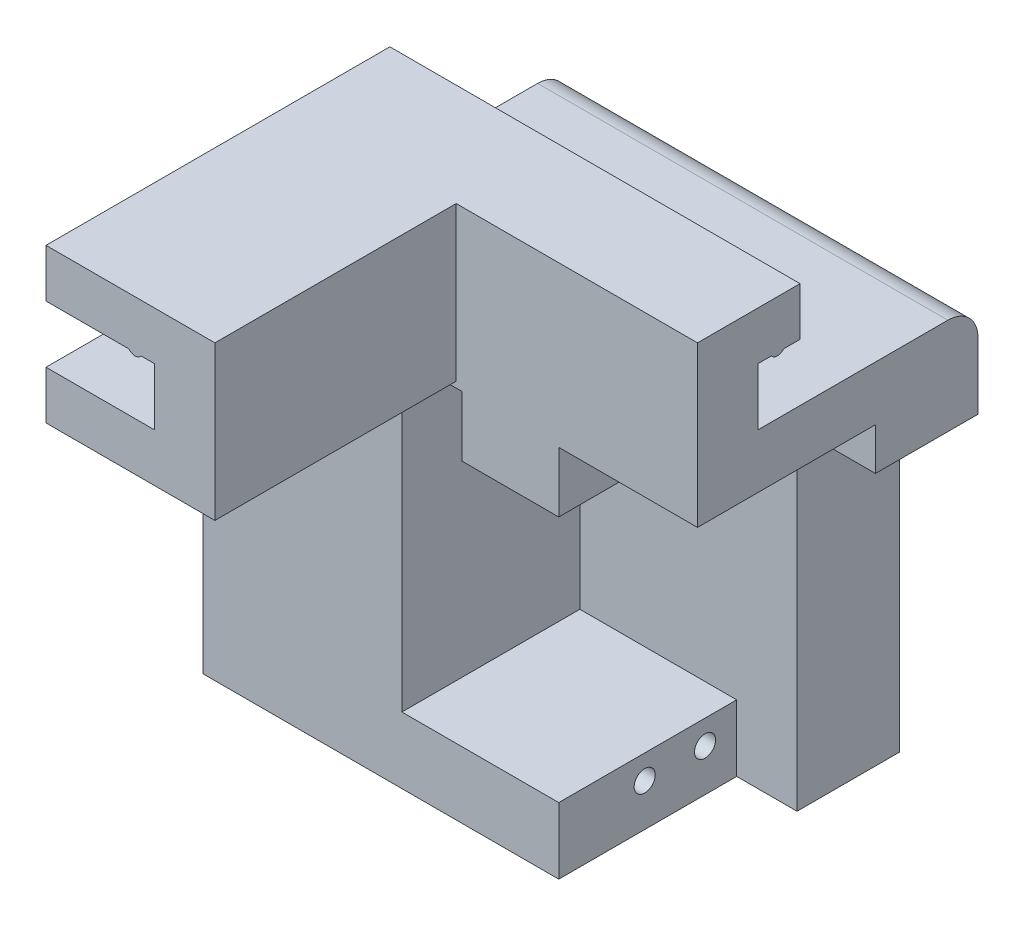
from build123d import *

# Parameters (mm, degrees)
BOSS_EXTRUDE1_DEPTH = 50
SKETCH2_W           = 7
SKETCH2_H           = 8
BOSS_EXTRUDE2_DEPTH = 50
SKETCH2_3_W         = 7
SKETCH2_3_H         = 8
BOSS_EXTRUDE3_DEPTH = 18
SKETCH3_W           = 10
SKETCH3_H           = 63
SKETCH3_W_2         = 7
SKETCH3_H_2         = 8
BOSS_EXTRUDE4_DEPTH = 82
FILLET1_R           = 5
SKETCH4_W           = 49
SKETCH4_H           = 29.5
CUT_EXTRUDE1_DEPTH  = 63
SKETCH5_W           = 29.5
SKETCH5_H           = 11
BOSS_EXTRUDE5_DEPTH = 49
CUT_EXTRUDE2_DEPTH  = 29.5
SKETCH6_R           = 1.75
CUT_EXTRUDE3_DEPTH  = 5
SKETCH6_6_R         = 0.75
CUT_EXTRUDE4_DEPTH  = 15
SKETCH8_W           = 18
SKETCH8_H           = 9.5
CUT_EXTRUDE5_DEPTH  = 40
SKETCH9_W           = 7
SKETCH9_H           = 9.5
CUT_EXTRUDE6_DEPTH  = 45
SKETCH10_W          = 10
SKETCH10_H          = 10
CUT_EXTRUDE7_DEPTH  = 29.5
SKETCH11_W          = 13
SKETCH11_H          = 48
SKETCH11_H_2        = 7
CUT_EXTRUDE8_DEPTH  = 124.13610356
SKETCH12_W          = 8
SKETCH12_H          = 10
CUT_EXTRUDE9_DEPTH  = 114.279521539
SKETCH13_W          = 10
SKETCH13_H          = 6
CUT_EXTRUDE10_DEPTH = 14
SKETCH15_W          = 14
SKETCH15_H          = 6
CUT_EXTRUDE11_DEPTH = 128.218316291
FILLET2_R           = 3


with BuildPart() as part:
    # Sketch1 → Boss-Extrude1 (new body)
    with BuildSketch(Plane.XY):
        with BuildLine():
            Line((-2.25, -8), (-4.25, -8))
            ThreePointArc((-4.25, -8), (-3.25, -8.5), (-2.25, -8))
        make_face()
        Polygon((10, -25.5), (10, 0), (0, 0), (-18, 0), (-18, -8), (0, -8), (0, -17.5), (-18, -17.5), (-18, -25.5), align=None)
    extrude(amount=BOSS_EXTRUDE1_DEPTH)

    # Sketch2 → Boss-Extrude2 (add)
    with BuildSketch(Plane(origin=(0, 0, 0), x_dir=(0, 0, -1), z_dir=(1, 0, 0))):
        Polygon((7, 0), (0, 0), (0, -8), (2.25, -8), (4.25, -8), (7, -8), align=None)
        Polygon((0, -8), (0, 0), (-10, 0), (-10, -25.5), (0, -25.5), (0, -17.5), align=None)
        with Locations((3.5, -21.5)):
            Rectangle(SKETCH2_W, SKETCH2_H)
        with BuildLine():
            Line((4.25, -8), (2.25, -8))
            ThreePointArc((2.25, -8), (3.25, -8.5), (4.25, -8))
        make_face()
    extrude(amount=BOSS_EXTRUDE2_DEPTH)

    # Sketch2_3 → Boss-Extrude3 (add)
    with BuildSketch(Plane(origin=(0, 0, 0), x_dir=(0, 0, -1), z_dir=(1, 0, 0))):
        Polygon((7, 0), (0, 0), (0, -8), (2.25, -8), (4.25, -8), (7, -8), align=None)
        with Locations((3.5, -21.5)):
            Rectangle(SKETCH2_3_W, SKETCH2_3_H)
    extrude(amount=-BOSS_EXTRUDE3_DEPTH)

    # Sketch3 → Boss-Extrude4 (add)
    with BuildSketch(Plane(origin=(50, 0, 0), x_dir=(0, 0, -1), z_dir=(1, 0, 0))):
        Polygon((36.5, -17.5), (7, -17.5), (7, -25.5), (0, -25.5), (0, -88.5), (36.5, -88.5), align=None)
        with Locations((-5, -57)):
            Rectangle(SKETCH3_W, SKETCH3_H)
        with Locations((3.5, -21.5)):
            Rectangle(SKETCH3_W_2, SKETCH3_H_2)
        with Locations((-5, -21.5)):
            Rectangle(SKETCH3_W, SKETCH3_H_2)
    extrude(amount=-BOSS_EXTRUDE4_DEPTH)

    # Fillet1
    fillet1_edges = [part.edges().sort_by_distance(p)[0] for p in [
        (-32, -17.5, -13.25),
        (-32, -53, -36.5),
        (9, -17.5, -36.5),
    ]]
    fillet(fillet1_edges, radius=FILLET1_R)

    # Sketch4 → Cut-Extrude1 (cut)
    with BuildSketch(Plane.XZ.offset(88.5)):
        with Locations((25.5, -4.75)):
            Rectangle(SKETCH4_W, SKETCH4_H)
    extrude(amount=-CUT_EXTRUDE1_DEPTH, mode=Mode.SUBTRACT)

    # Sketch5 → Boss-Extrude5 (add)
    with BuildSketch(Plane(origin=(50, 0, 0), x_dir=(0, 0, -1), z_dir=(1, 0, 0))):
        with Locations((4.75, -31)):
            Rectangle(SKETCH5_W, SKETCH5_H)
        with Locations((4.75, -83)):
            Rectangle(SKETCH5_W, SKETCH5_H)
    extrude(amount=-BOSS_EXTRUDE5_DEPTH)

    # Sketch7 → Cut-Extrude2 (cut)
    with BuildSketch(Plane.XY.offset(10)):
        Polygon((1, -36.5), (27, -36.5), (27, -26.5), (50, -26.5), (50, -88.5), (27, -88.5), (27, -77.5), (1, -77.5), align=None)
    extrude(amount=-CUT_EXTRUDE2_DEPTH, mode=Mode.SUBTRACT)

    # Sketch6 → Cut-Extrude3 (cut)
    with BuildSketch(Plane(origin=(27, 0, 0), x_dir=(0, 0, -1), z_dir=(1, 0, 0))):
        with Locations((4.25, -81.5)):
            Circle(SKETCH6_R)
        with Locations((14.25, -81.5)):
            Circle(SKETCH6_R)
        with Locations((14.25, -32.5)):
            Circle(SKETCH6_R)
        with Locations((4.25, -32.5)):
            Circle(SKETCH6_R)
    extrude(amount=-CUT_EXTRUDE3_DEPTH, mode=Mode.SUBTRACT)

    # Sketch6_6 → Cut-Extrude4 (cut)
    with BuildSketch(Plane(origin=(27, 0, 0), x_dir=(0, 0, -1), z_dir=(1, 0, 0))):
        with Locations((4.25, -81.5)):
            Circle(SKETCH6_6_R)
        with Locations((14.25, -81.5)):
            Circle(SKETCH6_6_R)
        with Locations((14.25, -32.5)):
            Circle(SKETCH6_6_R)
        with Locations((4.25, -32.5)):
            Circle(SKETCH6_6_R)
    extrude(amount=-CUT_EXTRUDE4_DEPTH, mode=Mode.SUBTRACT)

    # Sketch8 → Cut-Extrude5 (cut)
    with BuildSketch(Plane(origin=(0, 0, -7), x_dir=(-1, 0, 0), z_dir=(0, 0, -1))):
        with Locations((9, -12.75)):
            Rectangle(SKETCH8_W, SKETCH8_H)
    extrude(amount=-CUT_EXTRUDE5_DEPTH, mode=Mode.SUBTRACT)

    # Sketch9 → Cut-Extrude6 (cut)
    with BuildSketch(Plane.ZY.offset(18)):
        with Locations((-3.5, -12.75)):
            Rectangle(SKETCH9_W, SKETCH9_H)
    extrude(amount=-CUT_EXTRUDE6_DEPTH, mode=Mode.SUBTRACT)

    # Sketch10 → Cut-Extrude7 (cut)
    with BuildSketch(Plane.XY.offset(10)):
        with Locations((6, -31.5)):
            Rectangle(SKETCH10_W, SKETCH10_H)
    extrude(amount=-CUT_EXTRUDE7_DEPTH, mode=Mode.SUBTRACT)

    # Sketch11 → Cut-Extrude8 (cut, through all)
    with BuildSketch(Plane.XY.offset(-19.5)):
        with Locations((43.5, -57.5)):
            Rectangle(SKETCH11_W, SKETCH11_H)
        with Locations((43.5, -85)):
            Rectangle(SKETCH11_W, SKETCH11_H_2)
    extrude(amount=-CUT_EXTRUDE8_DEPTH, mode=Mode.SUBTRACT)

    # Sketch12 → Cut-Extrude9 (cut, through all)
    with BuildSketch(Plane.XZ.offset(88.5)):
        with Locations((-28, -31.5)):
            Rectangle(SKETCH12_W, SKETCH12_H)
    extrude(amount=-CUT_EXTRUDE9_DEPTH, mode=Mode.SUBTRACT)

    # Sketch13 → Cut-Extrude10 (cut)
    with BuildSketch(Plane.ZY.offset(32)):
        with Locations((-31.5, -20.5)):
            Rectangle(SKETCH13_W, SKETCH13_H)
    extrude(amount=-CUT_EXTRUDE10_DEPTH, mode=Mode.SUBTRACT)

    # Sketch15 → Cut-Extrude11 (cut, through all)
    with BuildSketch(Plane(origin=(0, 0, -26.5), x_dir=(-1, 0, 0), z_dir=(0, 0, -1))):
        with Locations((25, -20.5)):
            Rectangle(SKETCH15_W, SKETCH15_H)
    extrude(amount=-CUT_EXTRUDE11_DEPTH, mode=Mode.SUBTRACT)

    # Fillet2
    fillet2_edges = [part.edges().sort_by_distance(p)[0] for p in [
        (-24, -56, -26.5),
        (-24, -23.5, -31.5),
        (-28, -23.5, -26.5),
    ]]
    fillet(fillet2_edges, radius=FILLET2_R)


solid = part.part
